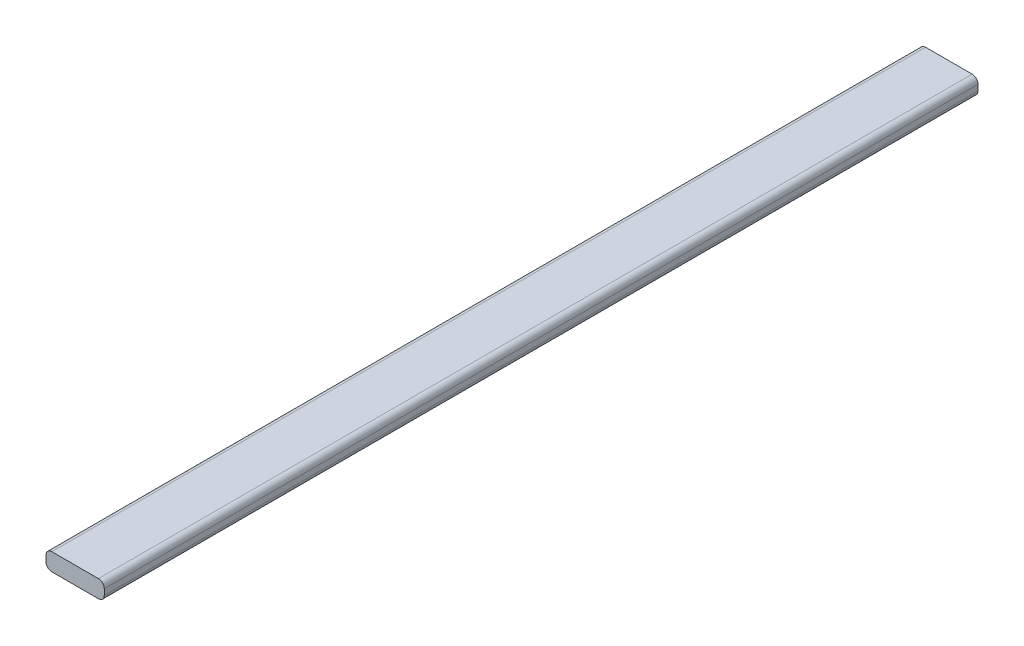
from build123d import *

# Parameters (mm, degrees)
BOSS_EXTRU_1_DEPTH = 150


with BuildPart() as part:
    # Esquisse1 → Boss.-Extru.1 (new body)
    with BuildSketch(Plane.XY):
        with BuildLine():
            Line((-4, 1.5), (4, 1.5))
            ThreePointArc((4, 1.5), (4.707106781, 1.207106781), (5, 0.5))
            Line((5, 0.5), (5, -0.5))
            ThreePointArc((5, -0.5), (4.707106781, -1.207106781), (4, -1.5))
            Line((4, -1.5), (-4, -1.5))
            ThreePointArc((-4, -1.5), (-4.707106781, -1.207106781), (-5, -0.5))
            Line((-5, -0.5), (-5, 0.5))
            ThreePointArc((-5, 0.5), (-4.707106781, 1.207106781), (-4, 1.5))
        make_face()
    extrude(amount=BOSS_EXTRU_1_DEPTH)


solid = part.part
